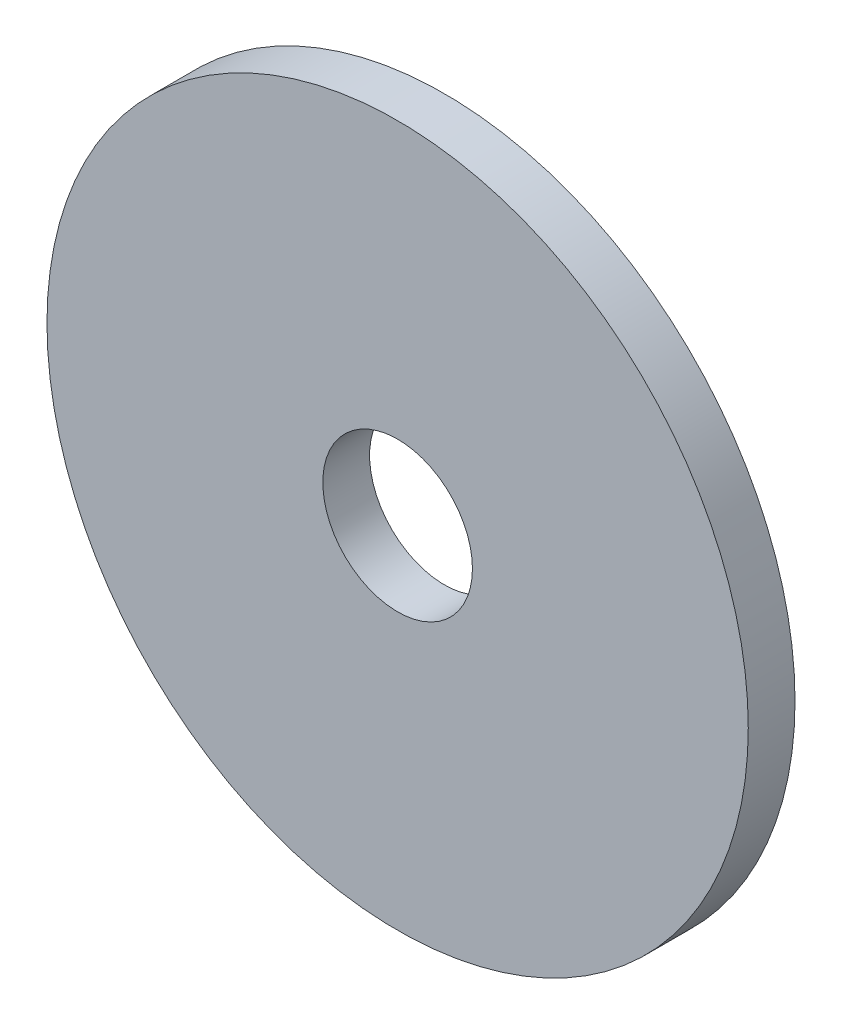
from build123d import *

# Parameters (mm, degrees)
SKETCH1_R                = 7.5
BOSS_EXTRUDE1_DEPTH      = 1
M3_CLEARANCE_HOLE1_D     = 3.2
M3_CLEARANCE_HOLE1_DEPTH = 10
M3_CLEARANCE_HOLE1_TIP   = 0.96137699


with BuildPart() as part:
    # Sketch1 → Boss-Extrude1 (new body)
    with BuildSketch(Plane.XY):
        Circle(SKETCH1_R)
    extrude(amount=BOSS_EXTRUDE1_DEPTH)

    # M3 Clearance Hole1
    with Locations(Plane.XY.offset(1)):
        with Locations((0, 0)):
            Hole(M3_CLEARANCE_HOLE1_D / 2, depth=M3_CLEARANCE_HOLE1_DEPTH)
            with Locations((0, 0, -(M3_CLEARANCE_HOLE1_DEPTH + M3_CLEARANCE_HOLE1_TIP / 2))):  # 118° drill point
                Cone(0, M3_CLEARANCE_HOLE1_D / 2, M3_CLEARANCE_HOLE1_TIP, mode=Mode.SUBTRACT)


solid = part.part
